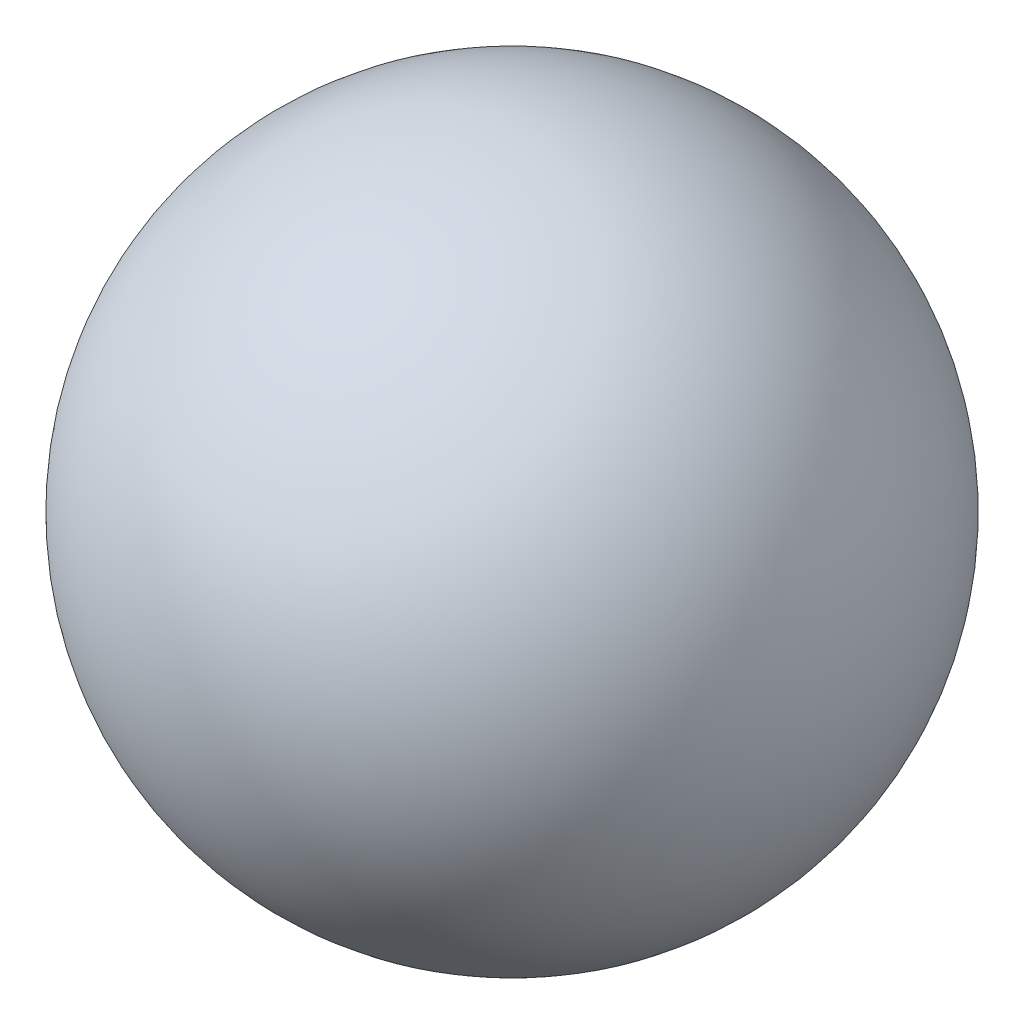
from build123d import *


with BuildPart() as part:
    # Sketch1 → Revolve1 (revolve)
    with BuildSketch(Plane.XY):
        with BuildLine():
            Line((0, 62.32239593), (0, -62.32239593))
            ThreePointArc((0, -62.32239593), (-62.32239593, 0), (0, 62.32239593))
        make_face()
    revolve(axis=Axis((0, 62.32239593, 0), (0, -1, 0)))


solid = part.part
